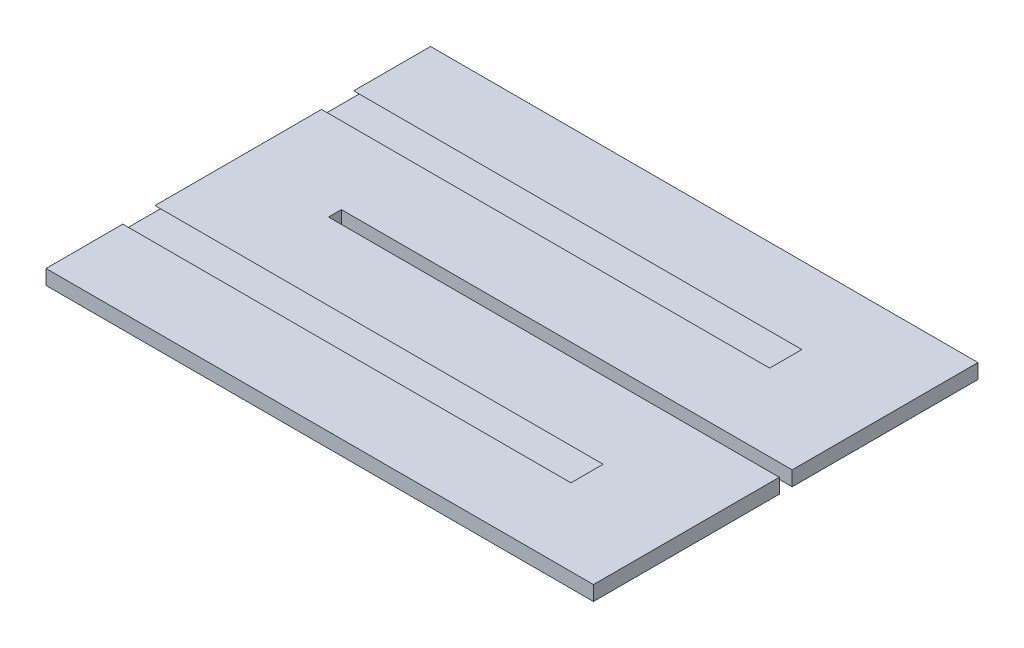
from build123d import *

# Parameters (mm, degrees)
BOSS_EXTRUDE1_DEPTH = 0.8
CUT_EXTRUDE1_START  = -2.6
CUT_EXTRUDE1_DEPTH  = 24.5
SKETCH4_W           = 10.1
SKETCH4_H           = 0.8
BOSS_EXTRUDE2_DEPTH = 2.8


with BuildPart() as part:
    # Sketch1 → Boss-Extrude1 (new body)
    with BuildSketch(Plane(origin=(0, 0, 0), x_dir=(1, 0, 0), z_dir=(0, 1, 0))):
        Polygon((13.478240741, 10.45), (-13.478240741, 10.45), (-13.478240741, -10.45), (13.478240741, -10.45), (13.478240741, -0.35), (-8.221759259, -0.35), (-8.221759259, 0.35), (13.478240741, 0.35), align=None)
    extrude(amount=BOSS_EXTRUDE1_DEPTH)

    # Sketch2 → Cut-Extrude1 (cut)
    with BuildSketch(Plane(origin=(13.478240741, 0, 0), x_dir=(0, 0, -1), z_dir=(1, 0, 0)).offset(CUT_EXTRUDE1_START)):
        Polygon((-7.025, 0.5), (-3.775, 0.5), (-4.525, 0.8), (-6.275, 0.8), align=None)
        Polygon((-7.025, 0.3), (-6.275, 0), (-4.525, 0), (-3.775, 0.3), align=None)
        Polygon((7.025, 0.3), (3.775, 0.3), (4.525, 0), (6.275, 0), align=None)
        Polygon((7.025, 0.5), (6.275, 0.8), (4.525, 0.8), (3.775, 0.5), align=None)
    extrude(amount=-CUT_EXTRUDE1_DEPTH, mode=Mode.SUBTRACT)

    # Sketch4 → Boss-Extrude2 (add)
    with BuildSketch(Plane(origin=(13.478240741, 0, 0), x_dir=(0, 0, -1), z_dir=(1, 0, 0))):
        with Locations((-5.4, 0.4)):
            Rectangle(SKETCH4_W, SKETCH4_H)
        with Locations((5.4, 0.4)):
            Rectangle(SKETCH4_W, SKETCH4_H)
    extrude(amount=BOSS_EXTRUDE2_DEPTH)


solid = part.part
